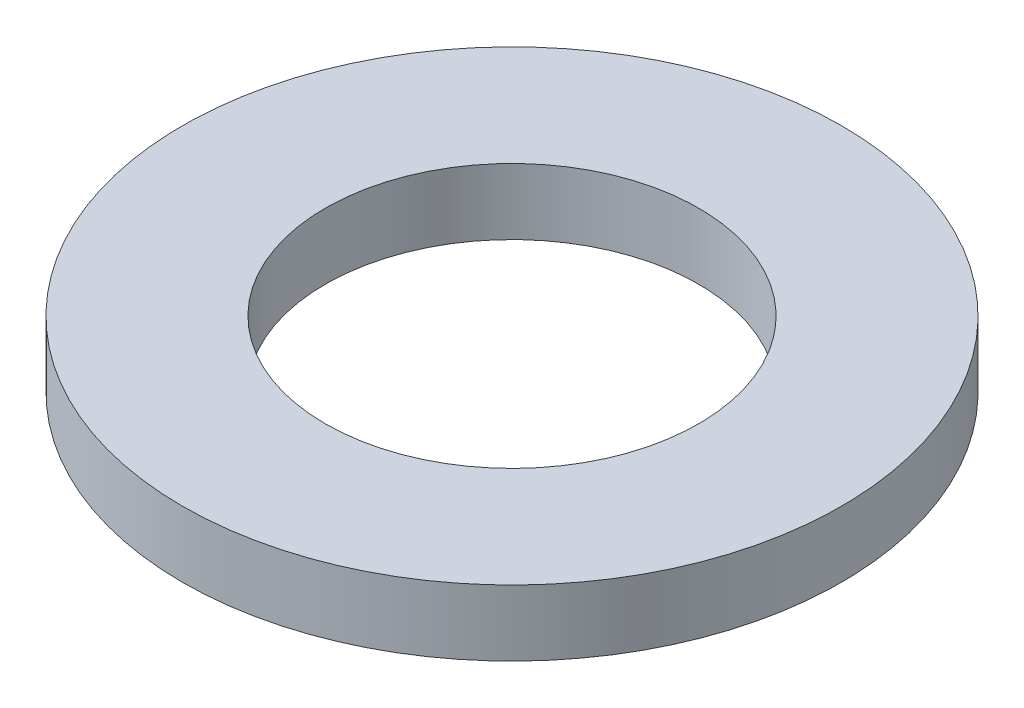
from build123d import *

# Parameters (mm, degrees)
SKETCH1_R           = 15
SKETCH1_R_2         = 8.5
BOSS_EXTRUDE1_DEPTH = 1.5


with BuildPart() as part:
    # Sketch1 → Boss-Extrude1 (new body, symmetric)
    with BuildSketch(Plane(origin=(0, 0, 0), x_dir=(1, 0, 0), z_dir=(0, 1, 0))):
        Circle(SKETCH1_R)
        Circle(SKETCH1_R_2, mode=Mode.SUBTRACT)
    extrude(amount=BOSS_EXTRUDE1_DEPTH, both=True)


solid = part.part
